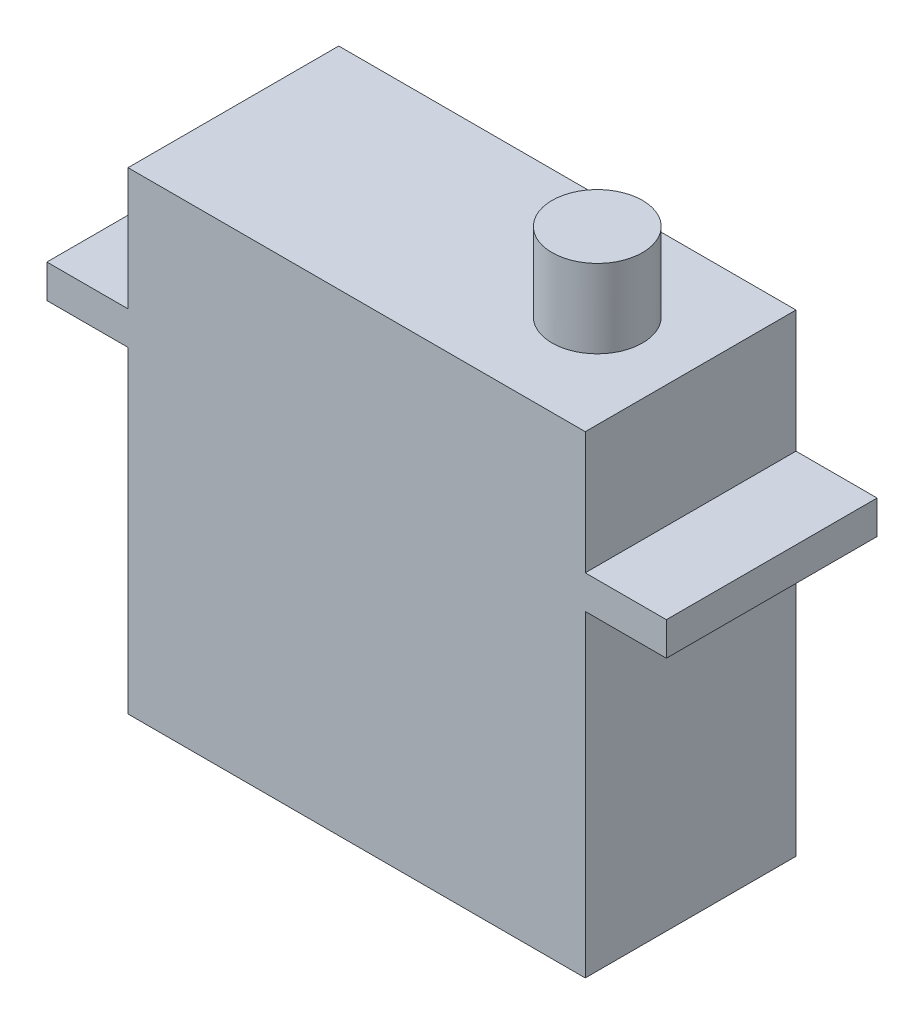
from build123d import *

# Parameters (mm, degrees)
SKETCH1_W           = 29.21
SKETCH1_H           = 30.226
BOSS_EXTRUDE1_DEPTH = 6.731
SKETCH2_W           = 5.1816
SKETCH2_H           = 2.1336
BOSS_EXTRUDE2_DEPTH = 13.462
SKETCH3_R           = 2.88925
BOSS_EXTRUDE3_DEPTH = 5.0038


with BuildPart() as part:
    # Sketch1 → Boss-Extrude1 (new body, symmetric)
    with BuildSketch(Plane.XY):
        Rectangle(SKETCH1_W, SKETCH1_H)
    extrude(amount=BOSS_EXTRUDE1_DEPTH, both=True)

    # Sketch2 → Boss-Extrude2 (add)
    with BuildSketch(Plane.XY.offset(6.731)):
        with Locations((-17.1958, 6.2357)):
            Rectangle(SKETCH2_W, SKETCH2_H)
    boss_extrude2 = extrude(amount=-BOSS_EXTRUDE2_DEPTH)

    # Mirror1: Boss-Extrude2 across plane
    add(boss_extrude2.mirror(Plane(origin=(0, 0, 0), x_dir=(0, 0, 1), z_dir=(1, 0, 0))))

    # Sketch3 → Boss-Extrude3 (add)
    with BuildSketch(Plane(origin=(0, 15.113, 0), x_dir=(1, 0, 0), z_dir=(0, 1, 0))):
        with Locations((8.64235, 0)):
            Circle(SKETCH3_R)
    extrude(amount=BOSS_EXTRUDE3_DEPTH)


solid = part.part
